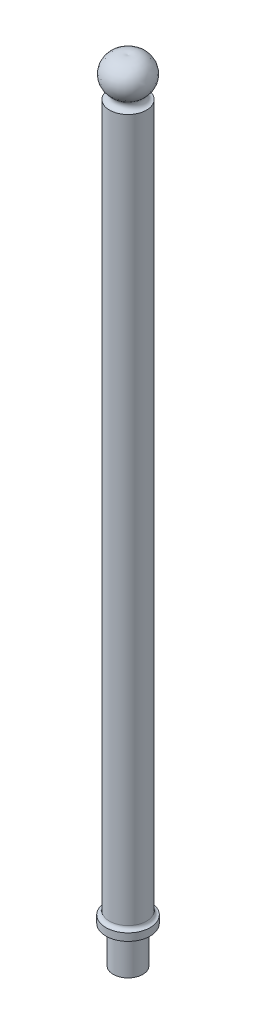
from build123d import *


with BuildPart() as part:
    # Sketch1 → Revolve1 (revolve)
    with BuildSketch(Plane.XY):
        with BuildLine():
            Line((-6, 0), (0, 0))
            Line((0, 0), (0, 320.752985543))
            ThreePointArc((0, 320.752985543), (-8.074390693, 317.189292472), (-6.242921278, 308.555555556))
            ThreePointArc((-6.242921278, 308.555555556), (-5.614381917, 306.333333333), (-7.5, 305))
            Line((-7.5, 305), (-7.5, 19.5))
            ThreePointArc((-7.5, 19.5), (-7.939339828, 18.439339828), (-9, 18))
            Line((-9, 18), (-9, 15))
            Line((-9, 15), (-6, 15))
            Line((-6, 15), (-6, 0))
        make_face()
    revolve(axis=Axis((0, 0, 0), (0, 1, 0)))


solid = part.part
